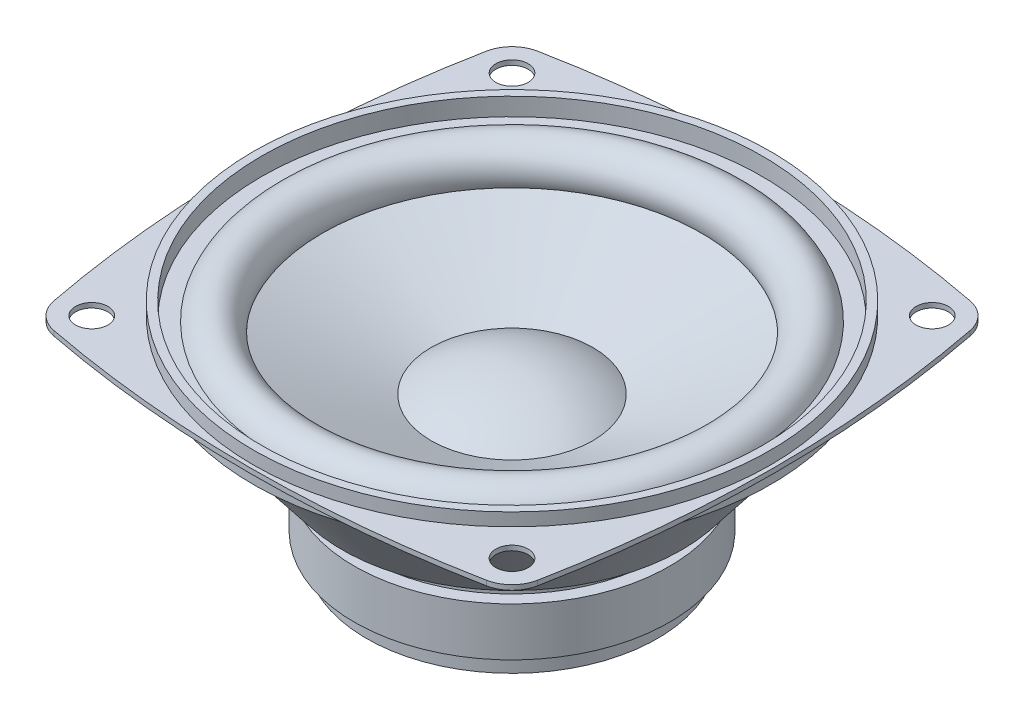
from build123d import *

# Parameters (mm, degrees)
SKETCH1_R           = 32
SKETCH1_R_2         = 2
BOSS_EXTRUDE1_DEPTH = 0.6
BOSS_EXTRUDE2_DEPTH = 12.5
BOSS_EXTRUDE3_START = -4
SKETCH4_R           = 1.056551939
BOSS_EXTRUDE3_DEPTH = 12


with BuildPart() as part:
    # Sketch1 → Boss-Extrude1 (new body)
    with BuildSketch(Plane(origin=(0, 0, 0), x_dir=(1, 0, 0), z_dir=(0, 1, 0))):
        with BuildLine():
            ThreePointArc((-26.76218395, 29.926713082), (-28.828427125, 28.828427125), (-29.926713082, 26.76218395))
            ThreePointArc((-29.926713082, 26.76218395), (-32.5, 0), (-29.926713082, -26.76218395))
            ThreePointArc((-29.926713082, -26.76218395), (-28.828427125, -28.828427125), (-26.76218395, -29.926713082))
            ThreePointArc((-26.76218395, -29.926713082), (0, -32.5), (26.76218395, -29.926713082))
            ThreePointArc((26.76218395, -29.926713082), (28.828427125, -28.828427125), (29.926713082, -26.76218395))
            ThreePointArc((29.926713082, -26.76218395), (32.5, 0), (29.926713082, 26.76218395))
            ThreePointArc((29.926713082, 26.76218395), (28.828427125, 28.828427125), (26.76218395, 29.926713082))
            ThreePointArc((26.76218395, 29.926713082), (0, 32.5), (-26.76218395, 29.926713082))
        make_face()
        Circle(SKETCH1_R, mode=Mode.SUBTRACT)
        with Locations((-26, 26)):
            Circle(SKETCH1_R_2, mode=Mode.SUBTRACT)
        with Locations((26, 26)):
            Circle(SKETCH1_R_2, mode=Mode.SUBTRACT)
        with Locations((26, -26)):
            Circle(SKETCH1_R_2, mode=Mode.SUBTRACT)
        with Locations((-26, -26)):
            Circle(SKETCH1_R_2, mode=Mode.SUBTRACT)
    extrude(amount=BOSS_EXTRUDE1_DEPTH)

    # Sketch2 → Revolve1 (revolve)
    with BuildSketch(Plane.XY):
        with BuildLine():
            Line((32, -1.5), (32, 2.2))
            Line((32, 2.2), (31, 2.2))
            Line((31, 2.2), (31, 0))
            Line((31, 0), (29, 0))
            ThreePointArc((29, 0), (25.085447071, 1.635932567), (23.449514503, -2.278620362))
            Line((23.449514503, -2.278620362), (10, -7.8))
            ThreePointArc((10, -7.8), (5.220153254, -5.566155818), (0, -4.8))
            Line((0, -4.8), (0, -25))
            Line((0, -25), (18, -25))
            Line((18, -25), (18, -22.5))
            Line((18, -22.5), (19.5, -22.5))
            Line((19.5, -22.5), (19.5, -16.5))
            Line((19.5, -16.5), (18, -16.5))
            Line((18, -16.5), (18, -14))
            Line((18, -14), (21, -14))
            Line((21, -14), (30, -2.5))
            Line((30, -2.5), (30, -1.5))
            Line((30, -1.5), (32, -1.5))
        make_face()
    revolve(axis=Axis((0, -17.479561209, 0), (0, -1, 0)))


with BuildPart() as body_2:
    # Sketch3 → Boss-Extrude2 (new body, symmetric)
    with BuildSketch(Plane(origin=(0, 0, 0), x_dir=(0, 0, -1), z_dir=(1, 0, 0))):
        Polygon((29.738486279, -6.079285725), (28.163476277, -4.846669202), (23.233010183, -11.14670921), (24.808020185, -12.379325733), align=None)
    extrude(amount=BOSS_EXTRUDE2_DEPTH, both=True)

    # Sketch4 → Boss-Extrude3 (add)
    with BuildSketch(Plane(origin=(12.5, 0, 0), x_dir=(0, 0, -1), z_dir=(1, 0, 0)).offset(BOSS_EXTRUDE3_START)):
        with Locations((27.273253232, -9.229305729)):
            Circle(SKETCH4_R)
    boss_extrude3 = extrude(amount=BOSS_EXTRUDE3_DEPTH)

    # Mirror1: Boss-Extrude3 across plane
    add(boss_extrude3.mirror(Plane(origin=(0, 0, 0), x_dir=(0, 0, 1), z_dir=(1, 0, 0))))


solid = Compound([part.part, body_2.part])
